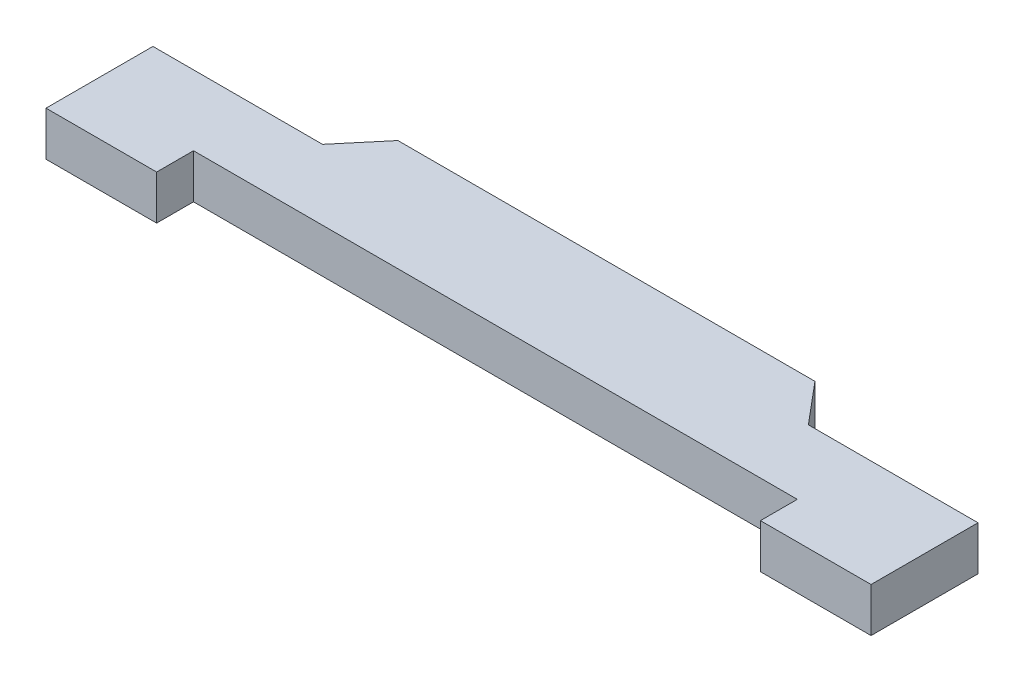
from build123d import *

# Parameters (mm, degrees)
BOSS_EXTRUDE1_DEPTH = 1.2


with BuildPart() as part:
    # Sketch1 → Boss-Extrude1 (new body)
    with BuildSketch(Plane(origin=(0, 0, 0), x_dir=(1, 0, 0), z_dir=(0, 1, 0))):
        Polygon((5.655, 3.010764443), (-5.655, 3.010764443), (-6.587042034, 1.9), (-11.187042034, 1.9), (-11.187042034, -1), (-8.187042034, -1), (-8.187042034, 0), (8.187042034, 0), (8.187042034, -1), (11.187042034, -1), (11.187042034, 1.9), (6.587042034, 1.9), align=None)
    extrude(amount=BOSS_EXTRUDE1_DEPTH)


solid = part.part
